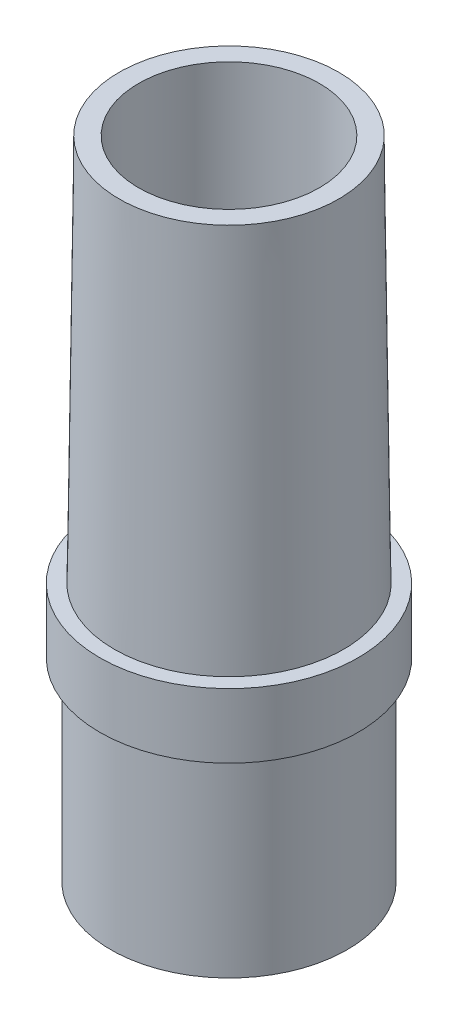
from build123d import *

# Parameters (mm, degrees)
SKETCH_1_R      = 20
SKETCH_1_R_2    = 14
EXTRUDE_1_DEPTH = 100
SKETCH_2_W      = 1.7
SKETCH_2_H      = 30


with BuildPart() as part:
    # Эскиз1 → Вытянуть-Тонкостенный1 (new body)
    with BuildSketch(Plane(origin=(0, 0, 0), x_dir=(1, 0, 0), z_dir=(0, 1, 0))):
        Circle(SKETCH_1_R)
        Circle(SKETCH_1_R_2, mode=Mode.SUBTRACT)
    extrude(amount=EXTRUDE_1_DEPTH)

    # Эскиз2 → Вырез-Повернуть1 (revolve, cut)
    with BuildSketch(Plane(origin=(0, 0, 0), x_dir=(0, 0, -1), z_dir=(1, 0, 0))):
        with Locations((19.15, 15)):
            Rectangle(SKETCH_2_W, SKETCH_2_H)
        Polygon((17, 100), (17.749980471, 40.001562317), (20, 40.001562317), (20, 100), align=None)
    revolve(axis=Axis((0, -5.85508708, 0), (0, 1, 0)), mode=Mode.SUBTRACT)


solid = part.part
